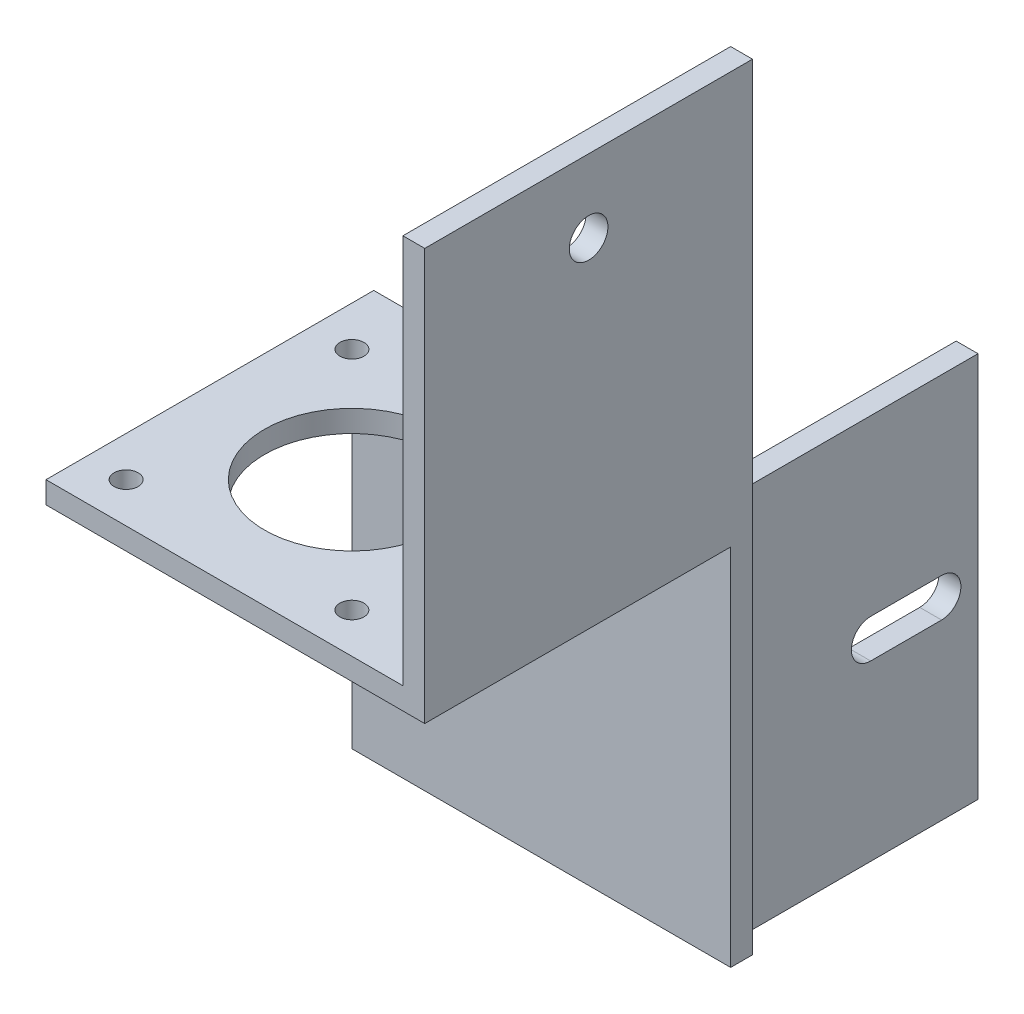
from build123d import *

# Parameters (mm, degrees)
SKETCH_1_W          = 42
SKETCH_1_H          = 53
EXTRUDE_1_DEPTH     = 3
SKETCH_2_W          = 42
SKETCH_2_H          = 3
EXTRUDE_2_DEPTH     = 42
SKETCH_3_R          = 12
SKETCH_3_R_2        = 1.65
CUT_EXTRUDE_1_DEPTH = 4
EXTRUDE_3_DEPTH     = 10
SKETCH_5_W          = 3
SKETCH_5_H          = 45
EXTRUDE_4_DEPTH     = 53.5
SKETCH_6_R          = 2.65
CUT_EXTRUDE_2_DEPTH = 20
SKETCH_7_W          = 3
SKETCH_7_H          = 53
EXTRUDE_5_DEPTH     = 33.96
CUT_EXTRUDE_4_DEPTH = 33.96


with BuildPart() as part:
    # 草图1 → 凸台-拉伸1 (new body)
    with BuildSketch(Plane.XY):
        with Locations((2.806034483, -15.140086207)):
            Rectangle(SKETCH_1_W, SKETCH_1_H)
    extrude(amount=EXTRUDE_1_DEPTH)

    # 草图2 → 凸台-拉伸2 (add)
    with BuildSketch(Plane.XY.offset(3)):
        with Locations((2.806034483, 9.859913793)):
            Rectangle(SKETCH_2_W, SKETCH_2_H)
    extrude(amount=EXTRUDE_2_DEPTH)

    # 草图3 → 切除-拉伸1 (cut, through all)
    with BuildSketch(Plane.XZ.offset(-8.359913793)):
        with Locations((2.806034483, 24)):
            Circle(SKETCH_3_R)
        with Locations((18.306034483, 39.5)):
            Circle(SKETCH_3_R_2)
        with Locations((18.306034483, 8.5)):
            Circle(SKETCH_3_R_2)
        with Locations((-12.693965517, 8.5)):
            Circle(SKETCH_3_R_2)
        with Locations((-12.693965517, 39.5)):
            Circle(SKETCH_3_R_2)
    extrude(amount=-CUT_EXTRUDE_1_DEPTH, mode=Mode.SUBTRACT)

    # 草图4 → 凸台-拉伸3 (add)
    with BuildSketch(Plane(origin=(23.806034483, 0, 0), x_dir=(0, 0, -1), z_dir=(1, 0, 0))):
        Polygon((-45, 8.359913793), (-3, 8.359913793), (-3, -41.640086207), (0, -41.640086207), (0, 8.359913793), (0, 11.359913793), (-45, 11.359913793), align=None)
    extrude(amount=EXTRUDE_3_DEPTH)

    # 草图5 → 凸台-拉伸4 (add)
    with BuildSketch(Plane(origin=(0, 11.359913793, 0), x_dir=(1, 0, 0), z_dir=(0, 1, 0))):
        with Locations((32.306034483, -22.5)):
            Rectangle(SKETCH_5_W, SKETCH_5_H)
    extrude(amount=EXTRUDE_4_DEPTH)

    # 草图6 → 切除-拉伸2 (cut)
    with BuildSketch(Plane(origin=(33.806034483, 0, 0), x_dir=(0, 0, -1), z_dir=(1, 0, 0))):
        with Locations((-22.5, 54.859913793)):
            Circle(SKETCH_6_R)
    extrude(amount=-CUT_EXTRUDE_2_DEPTH, mode=Mode.SUBTRACT)

    # 草图7 → 凸台-拉伸5 (add)
    with BuildSketch(Plane(origin=(0, 0, 0), x_dir=(-1, 0, 0), z_dir=(0, 0, -1))):
        with Locations((-29.306034483, -15.140086207)):
            Rectangle(SKETCH_7_W, SKETCH_7_H)
    extrude(amount=EXTRUDE_5_DEPTH)

    # 草图10 → 切除-拉伸4 (cut)
    with BuildSketch(Plane(origin=(30.806034483, 0, 0), x_dir=(0, 0, -1), z_dir=(1, 0, 0))):
        with BuildLine():
            Line((28.96, -17.807711285), (19.224876223, -17.807711285))
            ThreePointArc((19.224876223, -17.807711285), (16.574876223, -15.157711285), (19.224876223, -12.507711285))
            Line((19.224876223, -12.507711285), (28.96, -12.507711285))
            ThreePointArc((28.96, -12.507711285), (31.61, -15.157711285), (28.96, -17.807711285))
        make_face()
    extrude(amount=-CUT_EXTRUDE_4_DEPTH, mode=Mode.SUBTRACT)


solid = part.part
